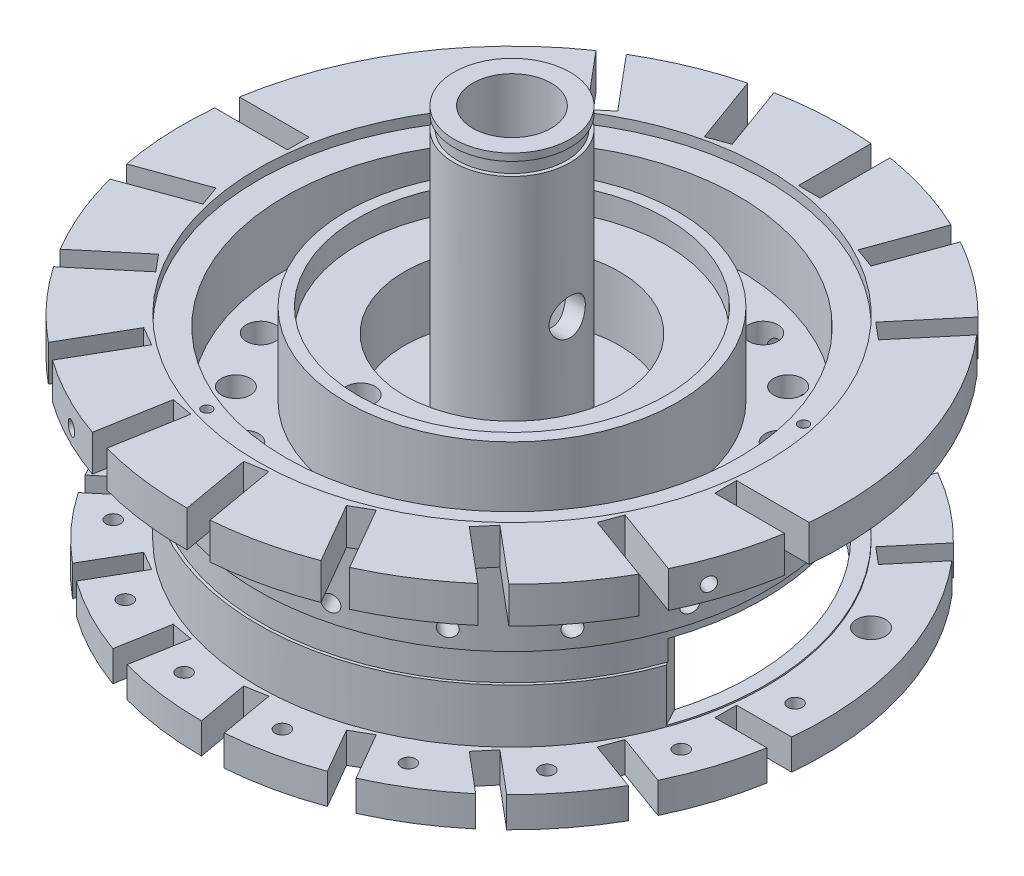
from build123d import *

# Parameters (mm, degrees)
SKETCH1_R                    = 21.5
BOSS_EXTRUDE1_DEPTH          = 2.1
SKETCH2_R                    = 17.5
BOSS_EXTRUDE2_DEPTH          = 10.9
SKETCH3_R                    = 22.7
BOSS_EXTRUDE3_DEPTH          = 2.5
SKETCH5_R                    = 11.4
BOSS_EXTRUDE4_DEPTH          = 0.5
SKETCH6_R                    = 4
BOSS_EXTRUDE5_DEPTH          = 12
SKETCH10_W                   = 0.25
SKETCH10_H                   = 0.9
SKETCH11_W                   = 0.2
SKETCH11_H                   = 2
SKETCH13_R                   = 50
CUT_EXTRUDE1_DEPTH           = 5
SKETCH13_3_R                 = 50
CUT_EXTRUDE2_DEPTH           = 5
CUT_EXTRUDE3_DEPTH           = 36.648702641
CIRPATTERN1_COUNT            = 10
CIRPATTERN1_ANGLE            = 180
CUT_EXTRUDE4_DEPTH           = 36.648702641
CIRPATTERN2_COUNT            = 5
CIRPATTERN2_ANGLE            = 80
F_2_0_2_DIAMETER_HOLE1_D     = 2
F_2_0_2_DIAMETER_HOLE2_D     = 2
SKETCH24_R                   = 2
CUT_EXTRUDE6_DEPTH           = 0.3
M1_TAPPED_HOLE1_D            = 0.7
M1_TAPPED_HOLE1_DEPTH        = 5
M1_TAPPED_HOLE1_TIP          = 0.210301217
F_2_0_2_DIAMETER_HOLE3_D     = 2
F_2_0_2_DIAMETER_HOLE3_DEPTH = 2.1
F_1_0_1_DIAMETER_HOLE1_D     = 1
F_1_0_1_DIAMETER_HOLE1_DEPTH = 2.1
M1_2X0_25_TAPPED_HOLE2_D     = 0.95
M1_2X0_25_TAPPED_HOLE2_DEPTH = 4.5
M1_2X0_25_TAPPED_HOLE2_TIP   = 0.285408794
M1_2X0_25_TAPPED_HOLE3_D     = 0.95
M1_2X0_25_TAPPED_HOLE3_DEPTH = 4.5
M1_2X0_25_TAPPED_HOLE3_TIP   = 0.285408794
M1_2X0_25_TAPPED_HOLE4_D     = 0.95
M1_2X0_25_TAPPED_HOLE4_DEPTH = 4.5
M1_2X0_25_TAPPED_HOLE4_TIP   = 0.285408794
M1_4X0_3_TAPPED_HOLE1_REACH  = 54.262
M1_4X0_3_TAPPED_HOLE1_BORE_R = 0.55
CIRPATTERN3_COUNT            = 10
CIRPATTERN3_ANGLE            = 180
M1_4X0_3_TAPPED_HOLE2_REACH  = 59.009
M1_4X0_3_TAPPED_HOLE2_BORE_R = 0.55
CIRPATTERN4_COUNT            = 5
CIRPATTERN4_ANGLE            = 80
SKETCH44_W                   = 1.606780411
SKETCH44_H                   = 1.25


with BuildPart() as part:
    # Sketch1 → Boss-Extrude1 (new body)
    with BuildSketch(Plane(origin=(0, 0, 0), x_dir=(1, 0, 0), z_dir=(0, 1, 0))):
        with Locations(Location((0, 0, 0), (0, 0, 270))):
            Circle(SKETCH1_R)
    extrude(amount=BOSS_EXTRUDE1_DEPTH)

    # Sketch2 → Boss-Extrude2 (add)
    with BuildSketch(Plane(origin=(0, 2.1, 0), x_dir=(1, 0, 0), z_dir=(0, 1, 0))):
        with Locations(Location((0, 0, 0), (0, 0, 270))):
            Circle(SKETCH2_R)
    extrude(amount=BOSS_EXTRUDE2_DEPTH)

    # Sketch3 → Boss-Extrude3 (add)
    with BuildSketch(Plane(origin=(0, 13, 0), x_dir=(1, 0, 0), z_dir=(0, 1, 0))):
        with Locations(Location((0, 0, 0), (0, 0, 270))):
            Circle(SKETCH3_R)
    extrude(amount=BOSS_EXTRUDE3_DEPTH)

    # Sketch4 → Cut-Revolve1 (revolve, cut)
    with BuildSketch(Plane.XY, mode=Mode.PRIVATE) as cut_revolve1_sk:
        Polygon((-16.5, 7.6), (-16.5, 0), (0, 0), (0, 8.4), (-4.5, 8.4), (-4.5, 7.4), (-6.5, 7.4), (-6.5, 7.6), align=None)
    revolve(cut_revolve1_sk.sketch.rotate(Axis((0, 0, 0), (0, 1, 0)), 270), axis=Axis((0, 0, 0), (0, 1, 0)), mode=Mode.SUBTRACT)

    # Sketch5 → Boss-Extrude4 (add)
    with BuildSketch(Plane(origin=(0, 15.5, 0), x_dir=(1, 0, 0), z_dir=(0, 1, 0))):
        with Locations(Location((0, 0, 0), (0, 0, 270))):
            Circle(SKETCH5_R)
    extrude(amount=BOSS_EXTRUDE4_DEPTH)

    # Sketch6 → Boss-Extrude5 (add)
    with BuildSketch(Plane(origin=(0, 16, 0), x_dir=(1, 0, 0), z_dir=(0, 1, 0))):
        with Locations(Location((0, 0, 0), (0, 0, 90))):
            Circle(SKETCH6_R)
    extrude(amount=BOSS_EXTRUDE5_DEPTH)

    # Sketch7 → Cut-Revolve2 (revolve, cut)
    with BuildSketch(Plane.XY, mode=Mode.PRIVATE) as cut_revolve2_sk:
        Polygon((17.5, 16), (17.5, 14.8), (15.6, 14.8), (15.6, 10.4), (11.4, 10.4), (11.4, 16), align=None)
    revolve(cut_revolve2_sk.sketch.rotate(Axis((0, 28, 0), (0, -1, 0)), 90), axis=Axis((0, 28, 0), (0, -1, 0)), mode=Mode.SUBTRACT)

    # Sketch9 → Cut-Revolve3 (revolve, cut)
    with BuildSketch(Plane.XY, mode=Mode.PRIVATE) as cut_revolve3_sk:
        Polygon((-10.6, 16), (-10.6, 14.4), (-7.4, 14.4), (-7.4, 10), (-4, 10), (-4, 16), align=None)
    revolve(cut_revolve3_sk.sketch.rotate(Axis((0, 0, 0), (0, 1, 0)), 270), axis=Axis((0, 0, 0), (0, 1, 0)), mode=Mode.SUBTRACT)

    # Sketch10 → Cut-Revolve4 (revolve, cut)
    with BuildSketch(Plane.XY, mode=Mode.PRIVATE) as cut_revolve4_sk:
        with Locations((3.875, 27.05)):
            Rectangle(SKETCH10_W, SKETCH10_H)
    revolve(cut_revolve4_sk.sketch.rotate(Axis((0, 28, 0), (0, -1, 0)), 270), axis=Axis((0, 28, 0), (0, -1, 0)), mode=Mode.SUBTRACT)

    # Sketch11 → Cut-Revolve5 (revolve, cut)
    with BuildSketch(Plane.XY, mode=Mode.PRIVATE) as cut_revolve5_sk:
        with Locations((17.4, 6.8)):
            Rectangle(SKETCH11_W, SKETCH11_H)
    revolve(cut_revolve5_sk.sketch.rotate(Axis((0, 0, 0), (0, 1, 0)), 90), axis=Axis((0, 0, 0), (0, 1, 0)), mode=Mode.SUBTRACT)

    # Sketch12 → Cut-Revolve6 (revolve, cut)
    with BuildSketch(Plane.XY, mode=Mode.PRIVATE) as cut_revolve6_sk:
        Polygon((0, 28), (2.7, 28), (2.7, 23), (2.75, 23), (2.75, 13), (2.7, 13), (2.7, 8.4), (0, 8.4), align=None)
    revolve(cut_revolve6_sk.sketch.rotate(Axis((0, 28, 0), (0, -1, 0)), 90), axis=Axis((0, 28, 0), (0, -1, 0)), mode=Mode.SUBTRACT)

    # Sketch13 → Cut-Extrude1 (cut)
    with BuildSketch(Plane(origin=(0, 2.2, 0), x_dir=(1, 0, 0), z_dir=(0, 1, 0))):
        with Locations((60.305016924, 18.229232945)):
            Circle(SKETCH13_R)
    extrude(amount=CUT_EXTRUDE1_DEPTH, mode=Mode.SUBTRACT)

    # Sketch13_3 → Cut-Extrude2 (cut)
    with BuildSketch(Plane(origin=(0, 2.2, 0), x_dir=(1, 0, 0), z_dir=(0, 1, 0))):
        with Locations((0.198778438, 62.999686405)):
            Circle(SKETCH13_3_R)
    extrude(amount=CUT_EXTRUDE2_DEPTH, mode=Mode.SUBTRACT)

    # Sketch14 → Cut-Extrude3 (cut, through all)
    with BuildSketch(Plane(origin=(0, 15.5, 0), x_dir=(1, 0, 0), z_dir=(0, 1, 0))):
        with BuildLine():
            Line((17.6, -2.13), (22.599847345, -2.13))
            ThreePointArc((22.599847345, -2.13), (22.516358213, -2.881599007), (22.40788031, -3.63))
            Line((22.40788031, -3.63), (17.6, -3.63))
            Line((17.6, -3.63), (17.6, -2.13))
        make_face()
    cut_extrude3 = extrude(amount=-CUT_EXTRUDE3_DEPTH, mode=Mode.SUBTRACT)

    # CirPattern1: Cut-Extrude3 ×10 about axis
    cirpattern1_axis = Axis((0, 0, 0), (0, -1, 0))
    for i in range(1, CIRPATTERN1_COUNT):
        add(cut_extrude3.rotate(cirpattern1_axis, i * CIRPATTERN1_ANGLE / (CIRPATTERN1_COUNT - 1)), mode=Mode.SUBTRACT)

    # Sketch17 → Cut-Extrude4 (cut, through all)
    with BuildSketch(Plane(origin=(0, 15.5, 0), x_dir=(1, 0, 0), z_dir=(0, 1, 0))):
        with BuildLine():
            Line((16.158576518, 15.943349865), (12.944736594, 12.11324459))
            Line((12.944736594, 12.11324459), (14.093803259, 11.149063176))
            Line((14.093803259, 11.149063176), (17.184249151, 14.832113171))
            ThreePointArc((17.184249151, 14.832113171), (16.680668981, 15.396274951), (16.158576518, 15.943349865))
        make_face()
    cut_extrude4 = extrude(amount=-CUT_EXTRUDE4_DEPTH, mode=Mode.SUBTRACT)

    # CirPattern2: Cut-Extrude4 ×5 about axis
    cirpattern2_axis = Axis((0, 0, 0), (0, 1, 0))
    for i in range(1, CIRPATTERN2_COUNT):
        add(cut_extrude4.rotate(cirpattern2_axis, i * CIRPATTERN2_ANGLE / (CIRPATTERN2_COUNT - 1)), mode=Mode.SUBTRACT)

    # Ø2.0 (2) Diameter Hole1 (through all)
    with Locations(Plane(origin=(0, 14.4, 0), x_dir=(1, 0, 0), z_dir=(0, 1, 0))):
        with Locations((13.5, 0), (12.685850381, -4.617271935), (10.341599982, -8.677632731), (6.75, -11.691342951), (2.344250399, -13.294904666), (-2.344250399, -13.294904666), (-6.75, -11.691342951), (-10.341599982, -8.677632731), (-12.685850381, -4.617271935), (-13.5, 0), (-12.685850381, 4.617271935), (-8.677632731, 10.341599982), (-4.617271935, 12.685850381), (0, 13.5), (4.617271935, 12.685850381), (8.677632731, 10.341599982), (11.691342951, 6.75)):
            Hole(F_2_0_2_DIAMETER_HOLE1_D / 2)

    # Ø2.0 (2) Diameter Hole2 (through all)
    with Locations(Plane(origin=(0, 14.4, 0), x_dir=(1, 0, 0), z_dir=(0, 1, 0))):
        with Locations((-1.562833599, -8.863269777), (-5.785088487, 6.894399988)):
            Hole(F_2_0_2_DIAMETER_HOLE2_D / 2)

    # Sketch24 → Cut-Extrude6 (cut)
    with BuildSketch(Plane.XZ.offset(-7.6)):
        with Locations(Location((-8.677632731, -10.341599982, 0), (0, 0, 270))):
            Circle(SKETCH24_R)
    extrude(amount=-CUT_EXTRUDE6_DEPTH, mode=Mode.SUBTRACT)

    # M1 Tapped Hole1
    with Locations(Plane(origin=(0, 14.8, 0), x_dir=(1, 0, 0), z_dir=(0, 1, 0))):
        with Locations((15.841183551, 4.24463234), (-5.609130351, -15.410958981), (-13.434093526, 9.406653556)):
            Hole(M1_TAPPED_HOLE1_D / 2, depth=M1_TAPPED_HOLE1_DEPTH)
            with Locations((0, 0, -(M1_TAPPED_HOLE1_DEPTH + M1_TAPPED_HOLE1_TIP / 2))):  # 118° drill point
                Cone(0, M1_TAPPED_HOLE1_D / 2, M1_TAPPED_HOLE1_TIP, mode=Mode.SUBTRACT)

    # Ø2.0 (2) Diameter Hole3
    with Locations(Plane(origin=(0, 2.1, 0), x_dir=(1, 0, 0), z_dir=(0, 1, 0))):
        with Locations((17.616493237, 7.117525275), (-12.713481521, 14.119751684), (-17.616493237, -7.117525275), (5.871322893, 18.07007381)):
            Hole(F_2_0_2_DIAMETER_HOLE3_D / 2, depth=F_2_0_2_DIAMETER_HOLE3_DEPTH)

    # Ø1.0 (1) Diameter Hole1
    with Locations(Plane(origin=(0, 2.1, 0), x_dir=(1, 0, 0), z_dir=(0, 1, 0))):
        with Locations((18.324006105, -6.669392795), (9.75, -16.887495374), (3.386139465, -19.203751184), (-3.386139465, -19.203751184), (-9.75, -16.887495374), (-14.937866641, -12.534358389), (14.937866641, -12.534358389), (19.5, 0)):
            Hole(F_1_0_1_DIAMETER_HOLE1_D / 2, depth=F_1_0_1_DIAMETER_HOLE1_DEPTH)

    # M1.2x0.25 Tapped Hole2
    with Locations(Plane(origin=(21.331022492, 15.5, 7.763857253), x_dir=(0.3420201433256695, 0, -0.9396926207859082), z_dir=(0.9396926207859082, 0, 0.3420201433256695))):
        with Locations((0, -1.5)):
            Hole(M1_2X0_25_TAPPED_HOLE2_D / 2, depth=M1_2X0_25_TAPPED_HOLE2_DEPTH)
            with Locations((0, 0, -(M1_2X0_25_TAPPED_HOLE2_DEPTH + M1_2X0_25_TAPPED_HOLE2_TIP / 2))):  # 118° drill point
                Cone(0, M1_2X0_25_TAPPED_HOLE2_D / 2, M1_2X0_25_TAPPED_HOLE2_TIP, mode=Mode.SUBTRACT)

    # M1.2x0.25 Tapped Hole3
    with Locations(Plane(origin=(-9.951025032, 15.5, 20.402624851), x_dir=(0.898794046299165, 0, 0.4383711467890815), z_dir=(-0.4383711467890815, 0, 0.898794046299165))):
        with Locations((0, -1.5)):
            Hole(M1_2X0_25_TAPPED_HOLE3_D / 2, depth=M1_2X0_25_TAPPED_HOLE3_DEPTH)
            with Locations((0, 0, -(M1_2X0_25_TAPPED_HOLE3_DEPTH + M1_2X0_25_TAPPED_HOLE3_TIP / 2))):  # 118° drill point
                Cone(0, M1_2X0_25_TAPPED_HOLE3_D / 2, M1_2X0_25_TAPPED_HOLE3_TIP, mode=Mode.SUBTRACT)

    # M1.2x0.25 Tapped Hole4
    with Locations(Plane(origin=(-21.331022492, 15.5, -7.763857253), x_dir=(-0.34202014332566244, 0, 0.9396926207859108), z_dir=(-0.9396926207859106, 0, -0.3420201433256624))):
        with Locations((0, -1.5)):
            Hole(M1_2X0_25_TAPPED_HOLE4_D / 2, depth=M1_2X0_25_TAPPED_HOLE4_DEPTH)
            with Locations((0, 0, -(M1_2X0_25_TAPPED_HOLE4_DEPTH + M1_2X0_25_TAPPED_HOLE4_TIP / 2))):  # 118° drill point
                Cone(0, M1_2X0_25_TAPPED_HOLE4_D / 2, M1_2X0_25_TAPPED_HOLE4_TIP, mode=Mode.SUBTRACT)

    # M1.4x0.3 Tapped Hole1 bore → M1.4x0.3 Tapped Hole1 (cut, up to next)
    with BuildSketch(Plane(origin=(17.6, 9, 4.617271935), x_dir=(0, 0, -1), z_dir=(1, 0, 0)), mode=Mode.PRIVATE) as m1_4x0_3_tapped_hole1_sk1:
        Circle(M1_4X0_3_TAPPED_HOLE1_BORE_R)
    m1_4x0_3_tapped_hole1_tool1 = extrude(m1_4x0_3_tapped_hole1_sk1.sketch, amount=-M1_4X0_3_TAPPED_HOLE1_REACH, mode=Mode.PRIVATE) & part.part
    m1_4x0_3_tapped_hole1 = m1_4x0_3_tapped_hole1_tool1.solids().sort_by_distance((17.6, 9, 4.617272))[0]
    add(m1_4x0_3_tapped_hole1, mode=Mode.SUBTRACT)

    # CirPattern3: M1.4x0.3 Tapped Hole1 ×10 about axis
    cirpattern3_axis = Axis((0, 59.913708499, 0), (0, -1, 0))
    for i in range(1, CIRPATTERN3_COUNT):
        add(m1_4x0_3_tapped_hole1.rotate(cirpattern3_axis, i * CIRPATTERN3_ANGLE / (CIRPATTERN3_COUNT - 1)), mode=Mode.SUBTRACT)

    # M1.4x0.3 Tapped Hole2 bore → M1.4x0.3 Tapped Hole2 (cut, up to next)
    with BuildSketch(Plane(origin=(11.31306193, 0, -13.482382199), x_dir=(-0.7660444431189788, 0, -0.6427876096865386), z_dir=(0.6427876096865386, 0, -0.7660444431189788)), mode=Mode.PRIVATE) as m1_4x0_3_tapped_hole2_sk1:
        with Locations((-4.617271935, 9)):
            Circle(M1_4X0_3_TAPPED_HOLE2_BORE_R)
    m1_4x0_3_tapped_hole2_tool1 = extrude(m1_4x0_3_tapped_hole2_sk1.sketch, amount=-M1_4X0_3_TAPPED_HOLE2_REACH, mode=Mode.PRIVATE) & part.part
    m1_4x0_3_tapped_hole2 = m1_4x0_3_tapped_hole2_tool1.solids().sort_by_distance((14.850097, 9, -10.514457))[0]
    add(m1_4x0_3_tapped_hole2, mode=Mode.SUBTRACT)

    # CirPattern4: M1.4x0.3 Tapped Hole2 ×5 about axis
    cirpattern4_axis = Axis((0, 59.913708499, 0), (0, 1, 0))
    for i in range(1, CIRPATTERN4_COUNT):
        add(m1_4x0_3_tapped_hole2.rotate(cirpattern4_axis, i * CIRPATTERN4_ANGLE / (CIRPATTERN4_COUNT - 1)), mode=Mode.SUBTRACT)

    # Sketch44 → Cut-Revolve7 (revolve, cut)
    with BuildSketch(Plane(origin=(0, 17.4, 0), x_dir=(-1, 0, 0), z_dir=(0, -1, 0)), mode=Mode.PRIVATE) as cut_revolve7_sk:
        with Locations((-3.196609795, 0.625)):
            Rectangle(SKETCH44_W, SKETCH44_H)
    revolve(cut_revolve7_sk.sketch.rotate(Axis((0, 17.4, 0), (1, 0, 0)), 180), axis=Axis((0, 17.4, 0), (1, 0, 0)), mode=Mode.SUBTRACT)


solid = part.part
